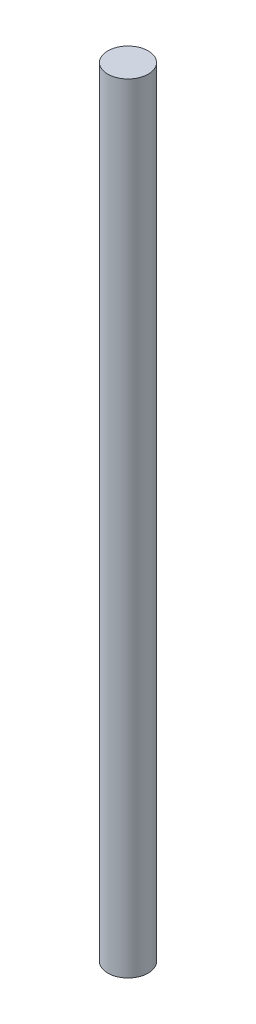
from build123d import *

# Parameters (mm, degrees)
SKETCH1_R           = 1
BOSS_EXTRUDE1_DEPTH = 38.55


with BuildPart() as part:
    # Sketch1 → Boss-Extrude1 (new body)
    with BuildSketch(Plane(origin=(0, 0, 0), x_dir=(1, 0, 0), z_dir=(0, 1, 0))):
        Circle(SKETCH1_R)
    extrude(amount=BOSS_EXTRUDE1_DEPTH)


solid = part.part
